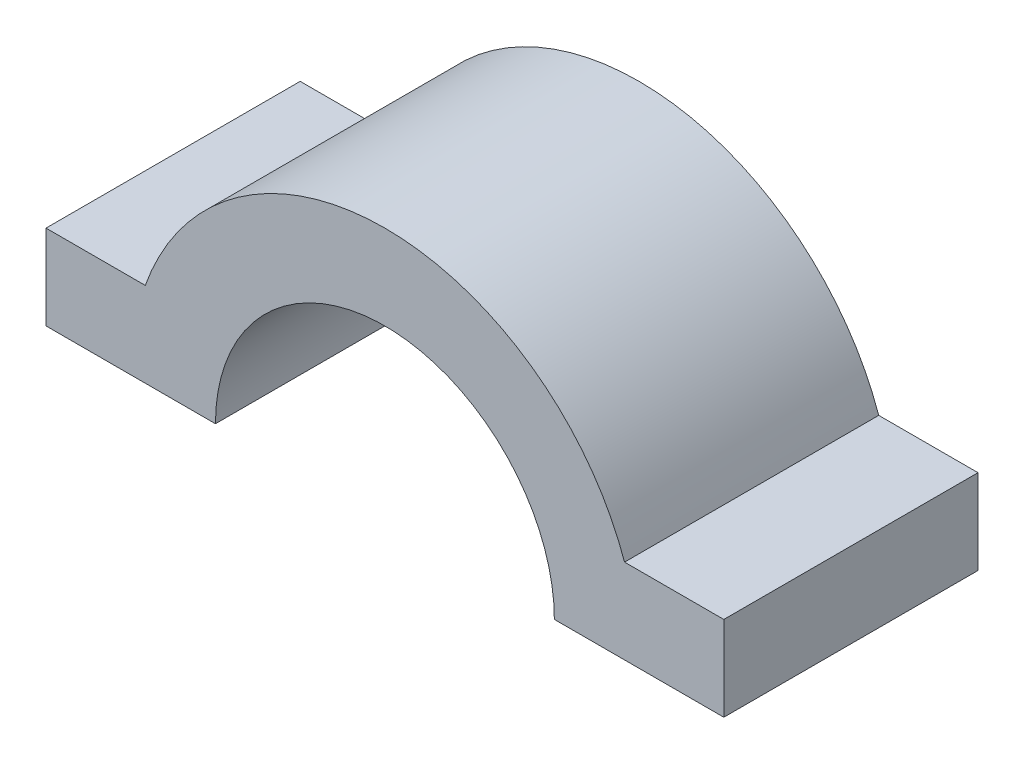
from build123d import *

# Parameters (mm, degrees)
CROQUIS1_W              = 40
CROQUIS1_H              = 15
SALIENTE_EXTRUIR1_DEPTH = 15
CROQUIS2_W              = 10
CROQUIS2_H              = 10
CORTAR_EXTRUIR2_DEPTH   = 15
CORTAR_EXTRUIR3_DEPTH   = 15
CORTAR_EXTRUIR4_DEPTH   = 15
SALIENTE_EXTRUIR2_DEPTH = 15


with BuildPart() as part:
    # Croquis1 → Saliente-Extruir1 (new body)
    with BuildSketch(Plane(origin=(0, 0, 0), x_dir=(1, 0, 0), z_dir=(0, 1, 0))):
        with Locations((20, -7.5)):
            Rectangle(CROQUIS1_W, CROQUIS1_H)
    extrude(amount=SALIENTE_EXTRUIR1_DEPTH)

    # Croquis2 → Cortar-Extruir2 (cut)
    with BuildSketch(Plane.XY.offset(15)):
        with Locations((5, 10)):
            Rectangle(CROQUIS2_W, CROQUIS2_H)
        with Locations((35, 10)):
            Rectangle(CROQUIS2_W, CROQUIS2_H)
    extrude(amount=-CORTAR_EXTRUIR2_DEPTH, mode=Mode.SUBTRACT)

    # Croquis5 → Cortar-Extruir3 (cut)
    with BuildSketch(Plane.XY.offset(15)):
        with BuildLine():
            ThreePointArc((30, 0), (20, 10), (10, 0))
            Line((10, 0), (30, 0))
        make_face()
        with BuildLine():
            Line((30, 0), (10, 0))
            ThreePointArc((10, 0), (20, -10), (30, 0))
        make_face()
    extrude(amount=-CORTAR_EXTRUIR3_DEPTH, mode=Mode.SUBTRACT)

    # Croquis6 → Cortar-Extruir4 (cut)
    with BuildSketch(Plane.XY.offset(15)):
        with BuildLine():
            Line((20, 15), (10, 15))
            Line((10, 15), (10, 11.180339887))
            ThreePointArc((10, 11.180339887), (14.647668653, 14.012585384), (20, 15))
        make_face()
        with BuildLine():
            Line((30, 15), (20, 15))
            ThreePointArc((20, 15), (25.352331347, 14.012585384), (30, 11.180339887))
            Line((30, 11.180339887), (30, 15))
        make_face()
    extrude(amount=-CORTAR_EXTRUIR4_DEPTH, mode=Mode.SUBTRACT)

    # Croquis7 → Saliente-Extruir2 (add)
    with BuildSketch(Plane.XY.offset(15)):
        with BuildLine():
            ThreePointArc((10, 11.180339887), (7.539669812, 8.351058113), (5.857864376, 5))
            Line((5.857864376, 5), (10, 5))
            Line((10, 5), (10, 11.180339887))
        make_face()
        with BuildLine():
            Line((30, 5), (34.142135624, 5))
            ThreePointArc((34.142135624, 5), (32.460330188, 8.351058113), (30, 11.180339887))
            Line((30, 11.180339887), (30, 5))
        make_face()
    extrude(amount=-SALIENTE_EXTRUIR2_DEPTH)


solid = part.part
